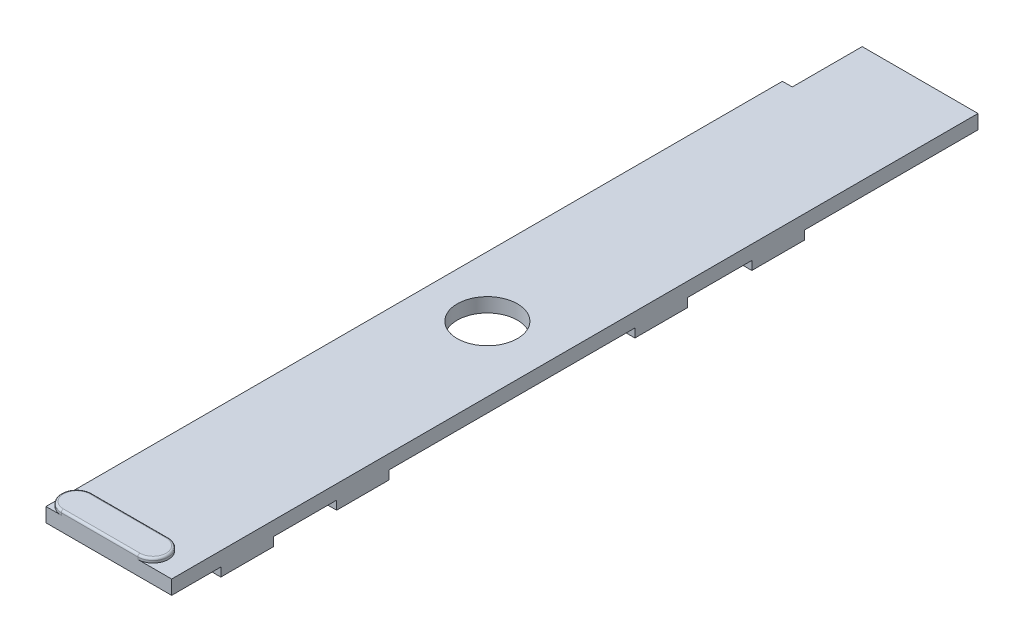
from build123d import *

# Parameters (mm, degrees)
SKETCH1_R           = 3.5
BOSS_EXTRUDE1_DEPTH = 1.651
BOSS_EXTRUDE2_DEPTH = 0.508
FILLET1_R           = 0.254
SKETCH3_W           = 4.699
SKETCH3_H           = 6.096
BOSS_EXTRUDE3_DEPTH = 1.016


with BuildPart() as part:
    # Sketch1 → Boss-Extrude1 (new body)
    with BuildSketch(Plane(origin=(0, 0, 0), x_dir=(1, 0, 0), z_dir=(0, 1, 0))):
        Polygon((0, 85.598), (0, 0), (14.605, 0), (14.605, 93.726), (1.143, 93.726), (1.143, 85.598), align=None)
        with Locations((7, 44.3)):
            Circle(SKETCH1_R, mode=Mode.SUBTRACT)
    extrude(amount=BOSS_EXTRUDE1_DEPTH)

    # Sketch2 → Boss-Extrude2 (add)
    with BuildSketch(Plane(origin=(0, 1.651, 0), x_dir=(1, 0, 0), z_dir=(0, 1, 0))):
        with BuildLine():
            Line((1.778, 3.556), (10.668, 3.556))
            ThreePointArc((10.668, 3.556), (12.446, 1.778), (10.668, 0))
            Line((10.668, 0), (1.778, 0))
            ThreePointArc((1.778, 0), (0, 1.778), (1.778, 3.556))
        make_face()
    extrude(amount=BOSS_EXTRUDE2_DEPTH)

    # Fillet1
    fillet1_edges = [part.edges().sort_by_distance(p)[0] for p in [
        (6.223, 2.159, -3.556),
        (6.223, 2.159, 0),
        (12.446, 2.159, -1.778),
        (0, 2.159, -1.778),
    ]]
    fillet(fillet1_edges, radius=FILLET1_R)

    # Sketch3 → Boss-Extrude3 (add)
    with BuildSketch(Plane.XZ):
        with Locations((12.2555, -8.763)):
            Rectangle(SKETCH3_W, SKETCH3_H)
        with Locations((12.2555, -22.225)):
            Rectangle(SKETCH3_W, SKETCH3_H)
        with Locations((12.2555, -56.896)):
            Rectangle(SKETCH3_W, SKETCH3_H)
        with Locations((12.2555, -70.485)):
            Rectangle(SKETCH3_W, SKETCH3_H)
        with Locations((2.3495, -75.946)):
            Rectangle(SKETCH3_W, SKETCH3_H)
        with Locations((2.3495, -62.357)):
            Rectangle(SKETCH3_W, SKETCH3_H)
        with Locations((2.3495, -27.686)):
            Rectangle(SKETCH3_W, SKETCH3_H)
        with Locations((2.3495, -14.224)):
            Rectangle(SKETCH3_W, SKETCH3_H)
    extrude(amount=BOSS_EXTRUDE3_DEPTH)


solid = part.part
